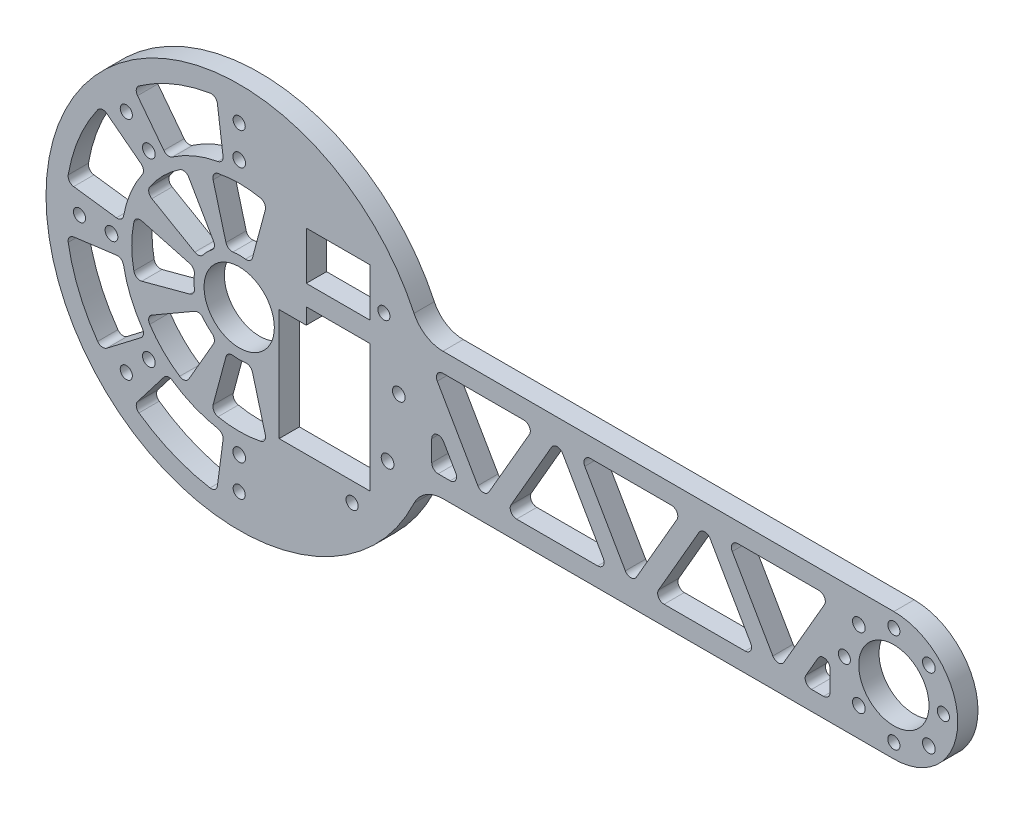
from build123d import *

# Parameters (mm, degrees)
SKETCH1_R                = 11
SKETCH1_R_2              = 1.89865
SKETCH1_R_3              = 1.9939
BOSS_EXTRUDE1_DEPTH      = 6.35
FILLET1_R                = 10
CUT_EXTRUDE1_DEPTH       = 7.35
FILLET2_R                = 2
SKETCH3_W                = 20
SKETCH3_H                = 15
CUT_EXTRUDE2_DEPTH       = 7.35
CUT_EXTRUDE3_DEPTH       = 7.35
FILLET4_R                = 2
CIRPATTERN2_COUNT        = 8
FILLET4_OF_CIRPATTERN2_R = 2
CUT_EXTRUDE4_DEPTH       = 7.35
FILLET5_R                = 2
CIRPATTERN3_COUNT        = 8
FILLET5_OF_CIRPATTERN3_R = 2
CHAMFER3_SIZE            = 2.301024407
CHAMFER3_SIZE2           = 2.00025
CHAMFER3_PART_2_SIZE     = 2.301024407
CHAMFER3_PART_2_SIZE2    = 2.00025
CHAMFER3_PART_3_SIZE     = 2.301024407
CHAMFER3_PART_3_SIZE2    = 2.00025
CHAMFER3_PART_4_SIZE     = 2.301024407
CHAMFER3_PART_4_SIZE2    = 2.00025
CHAMFER3_PART_5_SIZE     = 2.301024407
CHAMFER3_PART_5_SIZE2    = 2.00025
CHAMFER3_PART_6_SIZE     = 2.301024407
CHAMFER3_PART_6_SIZE2    = 2.00025
CHAMFER3_PART_7_SIZE     = 2.301024407
CHAMFER3_PART_7_SIZE2    = 2.00025


with BuildPart() as part:
    # Sketch1 → Boss-Extrude1 (new body)
    with BuildSketch(Plane.XY):
        with BuildLine():
            Line((57.098598932, -20), (205, -20))
            ThreePointArc((205, -20), (225, 0), (205, 20))
            Line((205, 20), (57.098598932, 20))
            ThreePointArc((57.098598932, 20), (-60.5, 0), (57.098598932, -20))
        make_face()
        Circle(SKETCH1_R, mode=Mode.SUBTRACT)
        with Locations((45.315389352, 21.130913087)):
            Circle(SKETCH1_R_2, mode=Mode.SUBTRACT)
        with Locations((46.467376211, -18.460307366)):
            Circle(SKETCH1_R_3, mode=Mode.SUBTRACT)
        with Locations((205, 0)):
            Circle(SKETCH1_R, mode=Mode.SUBTRACT)
        with Locations((49.978847504, 1.454235937)):
            Circle(SKETCH1_R_3, mode=Mode.SUBTRACT)
        with Locations((205, -15.5)):
            Circle(SKETCH1_R_2, mode=Mode.SUBTRACT)
        with Locations((215.960155108, -10.960155108)):
            Circle(SKETCH1_R_3, mode=Mode.SUBTRACT)
        with Locations((189.5, 0)):
            Circle(SKETCH1_R_2, mode=Mode.SUBTRACT)
        with Locations((194.039844892, -10.960155108)):
            Circle(SKETCH1_R_3, mode=Mode.SUBTRACT)
        with Locations((205, 15.5)):
            Circle(SKETCH1_R_2, mode=Mode.SUBTRACT)
        with Locations((194.039844892, 10.960155108)):
            Circle(SKETCH1_R_3, mode=Mode.SUBTRACT)
        with Locations((220.5, 0)):
            Circle(SKETCH1_R_2, mode=Mode.SUBTRACT)
        with Locations((215.960155108, 10.960155108)):
            Circle(SKETCH1_R_3, mode=Mode.SUBTRACT)
        with Locations((0, -40)):
            Circle(SKETCH1_R_3, mode=Mode.SUBTRACT)
        with Locations((0, -50)):
            Circle(SKETCH1_R_2, mode=Mode.SUBTRACT)
        with Locations((-28.284271247, -28.284271247)):
            Circle(SKETCH1_R_3, mode=Mode.SUBTRACT)
        with Locations((-35.355339059, -35.355339059)):
            Circle(SKETCH1_R_2, mode=Mode.SUBTRACT)
        with Locations((-40, 0)):
            Circle(SKETCH1_R_3, mode=Mode.SUBTRACT)
        with Locations((-50, 0)):
            Circle(SKETCH1_R_2, mode=Mode.SUBTRACT)
        with Locations((-28.284271247, 28.284271247)):
            Circle(SKETCH1_R_3, mode=Mode.SUBTRACT)
        with Locations((-35.355339059, 35.355339059)):
            Circle(SKETCH1_R_2, mode=Mode.SUBTRACT)
        with Locations((0, 40)):
            Circle(SKETCH1_R_3, mode=Mode.SUBTRACT)
        with Locations((0, 50)):
            Circle(SKETCH1_R_2, mode=Mode.SUBTRACT)
        with Locations((35.355339059, -35.355339059)):
            Circle(SKETCH1_R_2, mode=Mode.SUBTRACT)
    extrude(amount=BOSS_EXTRUDE1_DEPTH)

    # Fillet1
    fillet1_edges = [part.edges().sort_by_distance(p)[0] for p in [
        (57.098598932, 20, 3.175),
        (57.098598932, -20, 3.175),
    ]]
    fillet(fillet1_edges, radius=FILLET1_R)

    # Sketch2 → Cut-Extrude1 (cut, through all)
    with BuildSketch(Plane.XY.offset(6.35)):
        Polygon((60.292341855, 14), (92.62395693, 14), (76.458149392, -14), align=None)
        Polygon((83.386352623, -14), (99.55216016, 14), (115.717967697, -14), align=None)
        Polygon((106.48036339, 14), (122.646170928, -14), (138.811978465, 14), align=None)
        Polygon((129.574374158, -14), (145.740181695, 14), (161.905989232, -14), align=None)
        Polygon((152.668384925, 14), (168.834192463, -14), (185, 14), align=None)
        Polygon((60.292341855, 2), (60.292341855, -14), (69.529946162, -14), align=None)
        Polygon((185, 2), (185, -14), (175.762395693, -14), align=None)
    extrude(amount=-CUT_EXTRUDE1_DEPTH, mode=Mode.SUBTRACT)

    # Fillet2
    fillet2_edges = [part.edges().sort_by_distance(p)[0] for p in [
        (76.458149392, -14, 3.175),
        (60.292341855, 14, 3.175),
        (92.62395693, 14, 3.175),
        (115.717967697, -14, 3.175),
        (83.386352623, -14, 3.175),
        (99.55216016, 14, 3.175),
        (106.48036339, 14, 3.175),
        (138.811978465, 14, 3.175),
        (122.646170928, -14, 3.175),
        (161.905989232, -14, 3.175),
        (129.574374158, -14, 3.175),
        (145.740181695, 14, 3.175),
        (152.668384925, 14, 3.175),
        (185, 14, 3.175),
        (168.834192463, -14, 3.175),
        (60.292341855, 2, 3.175),
        (69.529946162, -14, 3.175),
        (60.292341855, -14, 3.175),
        (175.762395693, -14, 3.175),
        (185, 2, 3.175),
        (185, -14, 3.175),
    ]]
    fillet(fillet2_edges, radius=FILLET2_R)

    # Sketch3 → Cut-Extrude2 (cut, through all)
    with BuildSketch(Plane.XY):
        Polygon((12.5, -29.35), (41, -29.35), (41, 10.65), (21, 10.65), (21, 5.65), (12.5, 5.65), align=None)
        with Locations((31, 24.5)):
            Rectangle(SKETCH3_W, SKETCH3_H)
    extrude(amount=CUT_EXTRUDE2_DEPTH, mode=Mode.SUBTRACT)

    # Sketch4 → Cut-Extrude3 (cut, through all)
    with BuildSketch(Plane.XY.offset(6.35)):
        with BuildLine():
            Line((-13.691998588, 3.668759964), (-32.503404055, 8.709260868))
            ThreePointArc((-32.503404055, 8.709260868), (-33.65, 0), (-32.503404055, -8.709260868))
            Line((-32.503404055, -8.709260868), (-13.691998588, -3.668759964))
            ThreePointArc((-13.691998588, -3.668759964), (-14.175, 0), (-13.691998588, 3.668759964))
        make_face()
    cut_extrude3 = extrude(amount=-CUT_EXTRUDE3_DEPTH, mode=Mode.SUBTRACT)

    # Fillet4
    fillet4_edges = [part.edges().sort_by_distance(p)[0] for p in [
        (-13.691998588, 3.668759964, 3.175),
        (-13.691998588, -3.668759964, 3.175),
        (-32.503404055, -8.709260868, 3.175),
        (-32.503404055, 8.709260868, 3.175),
    ]]
    fillet(fillet4_edges, radius=FILLET4_R)

    # CirPattern2: Cut-Extrude3 ×8 about axis, 3 skipped
    cirpattern2_axis = Axis((0, 0, 0), (0, 0, -1))
    add([cut_extrude3.rotate(cirpattern2_axis, i * 360 / CIRPATTERN2_COUNT) for i in range(1, CIRPATTERN2_COUNT) if i not in (3, 4, 5)], mode=Mode.SUBTRACT)

    # Fillet4 of CirPattern2
    fillet4_of_cirpattern2_edges = [part.edges().sort_by_distance(p)[0] for p in [
        (-7.0875, 12.275910099, 3.175),
        (-12.275910099, 7.0875, 3.175),
        (-29.141754837, 16.825, 3.175),
        (-16.825, 29.141754837, 3.175),
        (3.668759964, 13.691998588, 3.175),
        (-3.668759964, 13.691998588, 3.175),
        (-8.709260868, 32.503404055, 3.175),
        (8.709260868, 32.503404055, 3.175),
        (-3.668759964, -13.691998588, 3.175),
        (3.668759964, -13.691998588, 3.175),
        (8.709260868, -32.503404055, 3.175),
        (-8.709260868, -32.503404055, 3.175),
        (-12.275910099, -7.0875, 3.175),
        (-7.0875, -12.275910099, 3.175),
        (-16.825, -29.141754837, 3.175),
        (-29.141754837, -16.825, 3.175),
    ]]
    fillet(fillet4_of_cirpattern2_edges, radius=FILLET4_OF_CIRPATTERN2_R)

    # Sketch5 → Cut-Extrude4 (cut, through all)
    with BuildSketch(Plane.XY.offset(6.35)):
        with BuildLine():
            Line((-43.098920211, 33.070964631), (-29.215236756, 22.417639623))
            ThreePointArc((-29.215236756, 22.417639623), (-34.021863785, 14.092317397), (-36.50995702, 4.806627029))
            Line((-36.50995702, 4.806627029), (-53.860242094, 7.090835392))
            ThreePointArc((-53.860242094, 7.090835392), (-50.189755604, 20.789277463), (-43.098920211, 33.070964631))
        make_face()
    cut_extrude4 = extrude(amount=-CUT_EXTRUDE4_DEPTH, mode=Mode.SUBTRACT)

    # Fillet5
    fillet5_edges = [part.edges().sort_by_distance(p)[0] for p in [
        (-29.215236756, 22.417639623, 3.175),
        (-36.50995702, 4.806627029, 3.175),
        (-53.860242094, 7.090835392, 3.175),
        (-43.098920211, 33.070964631, 3.175),
    ]]
    fillet(fillet5_edges, radius=FILLET5_R)

    # CirPattern3: Cut-Extrude4 ×8 about axis, 4 skipped
    cirpattern3_axis = Axis((0, 0, 0), (0, 0, -1))
    add([cut_extrude4.rotate(cirpattern3_axis, i * 360 / CIRPATTERN3_COUNT) for i in range(1, CIRPATTERN3_COUNT) if i not in (2, 3, 4, 5)], mode=Mode.SUBTRACT)

    # Fillet5 of CirPattern3
    fillet5_of_cirpattern3_edges = [part.edges().sort_by_distance(p)[0] for p in [
        (-4.806627029, 36.50995702, 3.175),
        (-22.417639623, 29.215236756, 3.175),
        (-33.070964631, 43.098920211, 3.175),
        (-7.090835392, 53.860242094, 3.175),
        (-22.417639623, -29.215236756, 3.175),
        (-4.806627029, -36.50995702, 3.175),
        (-7.090835392, -53.860242094, 3.175),
        (-33.070964631, -43.098920211, 3.175),
        (-36.50995702, -4.806627029, 3.175),
        (-29.215236756, -22.417639623, 3.175),
        (-43.098920211, -33.070964631, 3.175),
        (-53.860242094, -7.090835392, 3.175),
    ]]
    fillet(fillet5_of_cirpattern3_edges, radius=FILLET5_OF_CIRPATTERN3_R)

    # Chamfer3
    chamfer3_edges = [part.edges().sort_by_distance(p)[0] for p in [
        (43.416739352, 21.130913087, 0),
    ]]
    chamfer3_side = [part.faces().sort_by_distance(p)[0] for p in [
        (43.416739352, 21.130913087, 3.175),
    ]]
    chamfer(chamfer3_edges, length=CHAMFER3_SIZE, length2=CHAMFER3_SIZE2, reference=chamfer3_side[0])

    # Chamfer3 part 2
    chamfer3_part_2_edges = [part.edges().sort_by_distance(p)[0] for p in [
        (-1.89865, -50, 0),
    ]]
    chamfer3_part_2_side = [part.faces().sort_by_distance(p)[0] for p in [
        (-1.89865, -50, 3.175),
    ]]
    chamfer(chamfer3_part_2_edges, length=CHAMFER3_PART_2_SIZE, length2=CHAMFER3_PART_2_SIZE2, reference=chamfer3_part_2_side[0])

    # Chamfer3 part 3
    chamfer3_part_3_edges = [part.edges().sort_by_distance(p)[0] for p in [
        (-37.253989059, -35.355339059, 0),
    ]]
    chamfer3_part_3_side = [part.faces().sort_by_distance(p)[0] for p in [
        (-37.253989059, -35.355339059, 3.175),
    ]]
    chamfer(chamfer3_part_3_edges, length=CHAMFER3_PART_3_SIZE, length2=CHAMFER3_PART_3_SIZE2, reference=chamfer3_part_3_side[0])

    # Chamfer3 part 4
    chamfer3_part_4_edges = [part.edges().sort_by_distance(p)[0] for p in [
        (-51.89865, 0, 0),
    ]]
    chamfer3_part_4_side = [part.faces().sort_by_distance(p)[0] for p in [
        (-51.89865, 0, 3.175),
    ]]
    chamfer(chamfer3_part_4_edges, length=CHAMFER3_PART_4_SIZE, length2=CHAMFER3_PART_4_SIZE2, reference=chamfer3_part_4_side[0])

    # Chamfer3 part 5
    chamfer3_part_5_edges = [part.edges().sort_by_distance(p)[0] for p in [
        (-37.253989059, 35.355339059, 0),
    ]]
    chamfer3_part_5_side = [part.faces().sort_by_distance(p)[0] for p in [
        (-37.253989059, 35.355339059, 3.175),
    ]]
    chamfer(chamfer3_part_5_edges, length=CHAMFER3_PART_5_SIZE, length2=CHAMFER3_PART_5_SIZE2, reference=chamfer3_part_5_side[0])

    # Chamfer3 part 6
    chamfer3_part_6_edges = [part.edges().sort_by_distance(p)[0] for p in [
        (-1.89865, 50, 0),
    ]]
    chamfer3_part_6_side = [part.faces().sort_by_distance(p)[0] for p in [
        (-1.89865, 50, 3.175),
    ]]
    chamfer(chamfer3_part_6_edges, length=CHAMFER3_PART_6_SIZE, length2=CHAMFER3_PART_6_SIZE2, reference=chamfer3_part_6_side[0])

    # Chamfer3 part 7
    chamfer3_part_7_edges = [part.edges().sort_by_distance(p)[0] for p in [
        (33.456689059, -35.355339059, 0),
    ]]
    chamfer3_part_7_side = [part.faces().sort_by_distance(p)[0] for p in [
        (33.456689059, -35.355339059, 3.175),
    ]]
    chamfer(chamfer3_part_7_edges, length=CHAMFER3_PART_7_SIZE, length2=CHAMFER3_PART_7_SIZE2, reference=chamfer3_part_7_side[0])


solid = part.part
